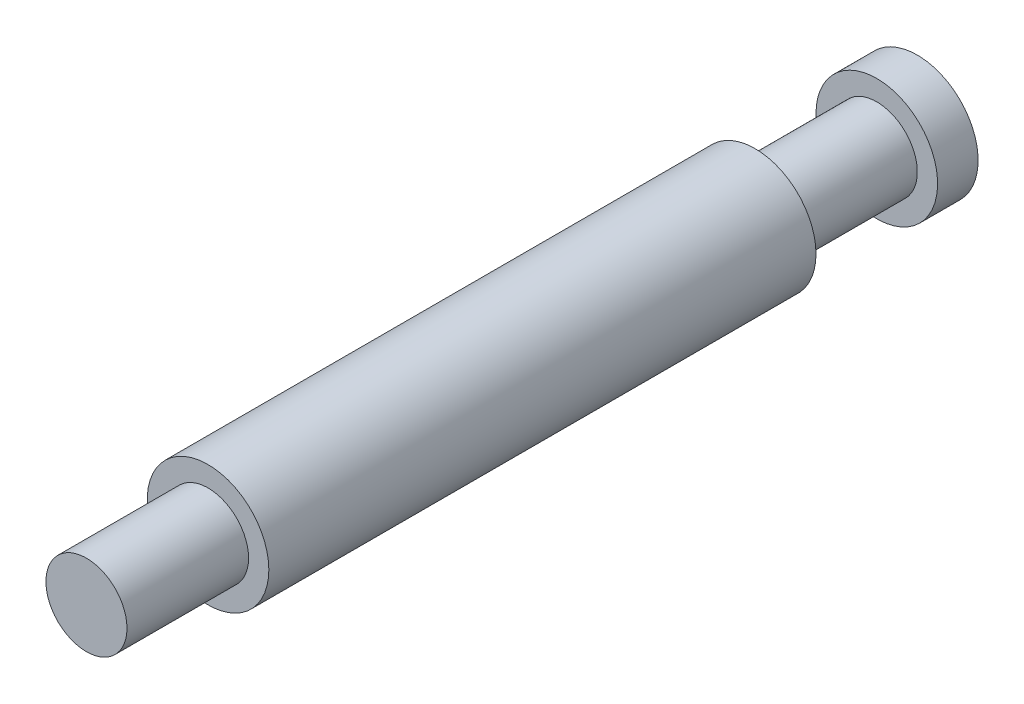
from build123d import *

# Parameters (mm, degrees)
SKETCH_1_R      = 1.5
EXTRUDE_1_DEPTH = 13.5
SKETCH_2_R      = 1
EXTRUDE_2_DEPTH = 3
SKETCH_3_R      = 1
EXTRUDE_3_DEPTH = 3
SKETCH_4_R      = 1.5
EXTRUDE_4_DEPTH = 1


with BuildPart() as part:
    # 草图1 → 凸台-拉伸1 (new body)
    with BuildSketch(Plane.XY):
        Circle(SKETCH_1_R)
    extrude(amount=EXTRUDE_1_DEPTH)

    # 草图2 → 凸台-拉伸2 (add)
    with BuildSketch(Plane.XY.offset(13.5)):
        Circle(SKETCH_2_R)
    extrude(amount=EXTRUDE_2_DEPTH)

    # 草图3 → 凸台-拉伸3 (add)
    with BuildSketch(Plane(origin=(0, 0, 0), x_dir=(-1, 0, 0), z_dir=(0, 0, -1))):
        Circle(SKETCH_3_R)
    extrude(amount=EXTRUDE_3_DEPTH)

    # 草图4 → 凸台-拉伸4 (add)
    with BuildSketch(Plane(origin=(0, 0, -3), x_dir=(-1, 0, 0), z_dir=(0, 0, -1))):
        Circle(SKETCH_4_R)
    extrude(amount=EXTRUDE_4_DEPTH)


solid = part.part
